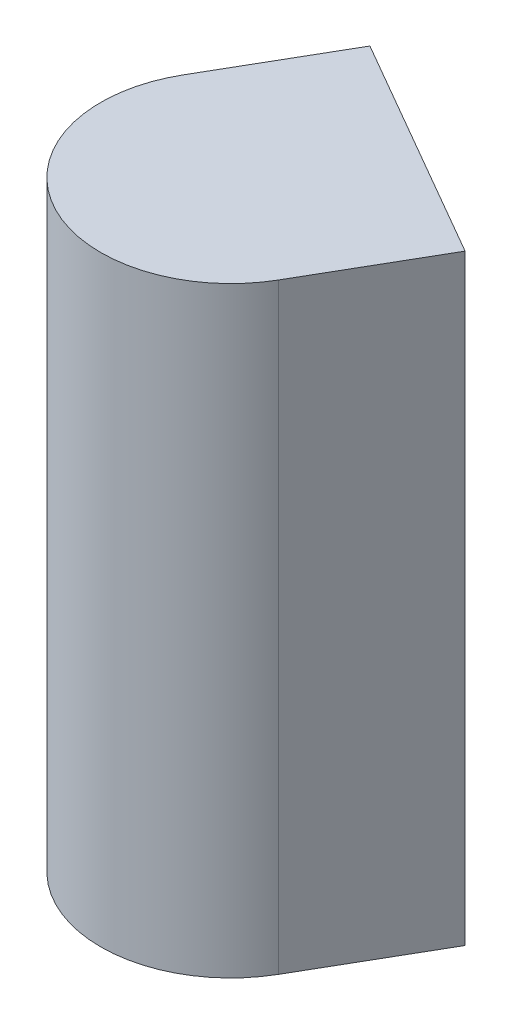
from build123d import *

# Parameters (mm, degrees)
BOSS_EXTRUDE1_DEPTH = 18.5


with BuildPart() as part:
    # Sketch1 → Boss-Extrude1 (new body)
    with BuildSketch(Plane(origin=(0, 0, 0), x_dir=(1, 0, 0), z_dir=(0, 1, 0))):
        with BuildLine():
            Line((16.138734818, -70.596878052), (14.035899162, -74.239097595))
            ThreePointArc((14.035899162, -74.239097595), (15.500001311, -79.70320007), (20.964103699, -78.239097595))
            Line((20.964103699, -78.239097595), (23.0669384, -74.596878052))
            Line((23.0669384, -74.596878052), (16.138734818, -70.596878052))
        make_face()
    extrude(amount=BOSS_EXTRUDE1_DEPTH)


solid = part.part
